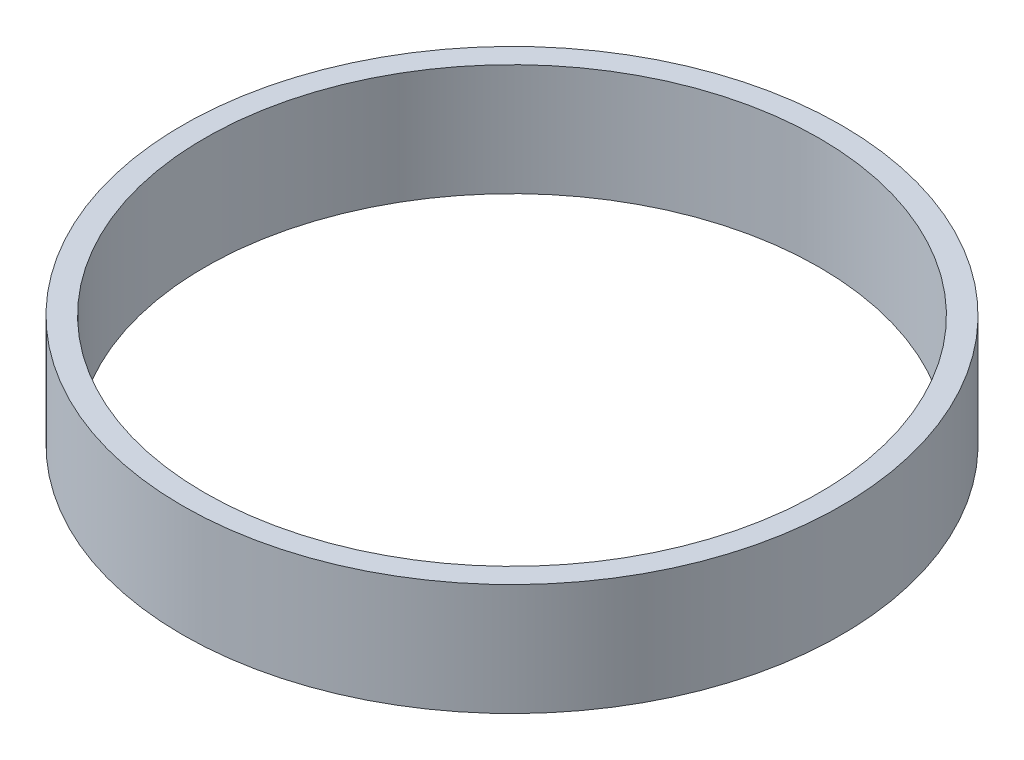
from build123d import *

# Parameters (mm, degrees)
SKETCH_1_R      = 29.5
SKETCH_1_R_2    = 27.5
EXTRUDE_1_DEPTH = 10


with BuildPart() as part:
    # Эскиз1 → Бобышка-Вытянуть1 (new body)
    with BuildSketch(Plane(origin=(0, 0, 0), x_dir=(1, 0, 0), z_dir=(0, 1, 0))):
        Circle(SKETCH_1_R)
        Circle(SKETCH_1_R_2, mode=Mode.SUBTRACT)
    extrude(amount=EXTRUDE_1_DEPTH)


solid = part.part
